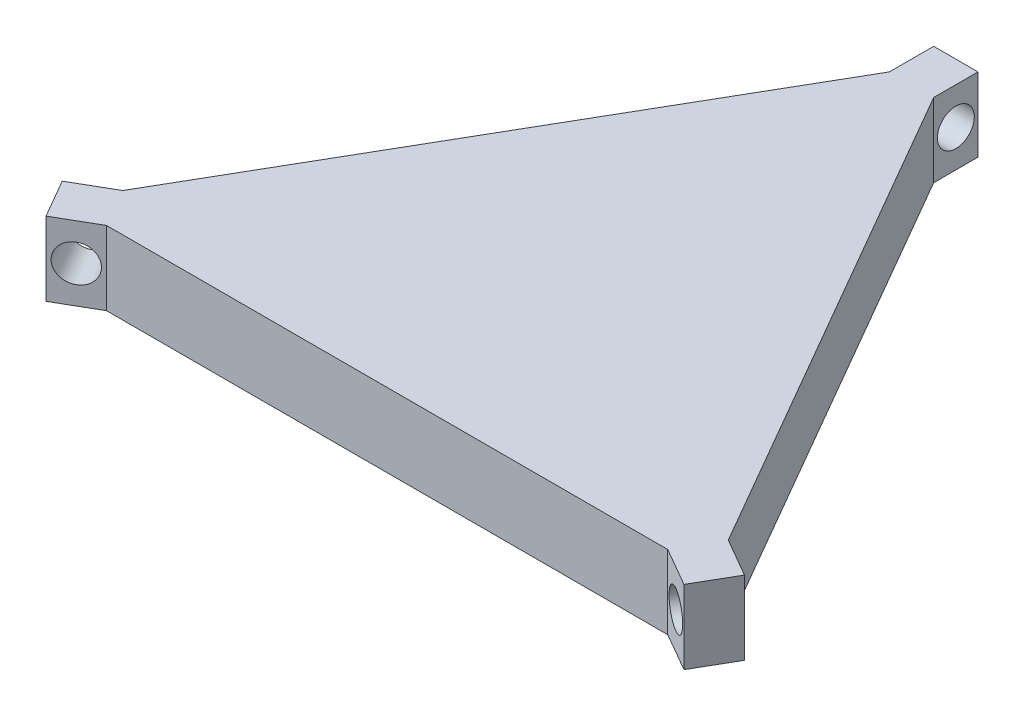
from build123d import *

# Parameters (mm, degrees)
BOSS_EXTRUDE1_DEPTH = 10
SKETCH2_R           = 2.5
CUT_EXTRUDE1_DEPTH  = 88.866025
SKETCH3_R           = 2.5
CUT_EXTRUDE2_DEPTH  = 6


with BuildPart() as part:
    # Sketch1 → Boss-Extrude1 (new body)
    with BuildSketch(Plane(origin=(0, 0, 0), x_dir=(1, 0, 0), z_dir=(0, 1, 0))):
        Polygon((-3, 71.01408311), (-41, 5.196152423), (-46.196152423, 2.196152423), (-43.196152423, -3), (-38, 0), (38, 0), (43.196152423, -3), (46.196152423, 2.196152423), (41, 5.196152423), (3, 71.01408311), (3, 77.01408311), (-3, 77.01408311), align=None)
    extrude(amount=BOSS_EXTRUDE1_DEPTH)

    # Sketch2 → Cut-Extrude1 (cut)
    with BuildSketch(Plane(origin=(-9.5, 0, -16.454482672), x_dir=(0.866025404, 0, -0.5), z_dir=(0.5, 0, 0.866025404))):
        with Locations((-35.908965344, 5)):
            Circle(SKETCH2_R)
    cut_extrude1 = extrude(amount=-CUT_EXTRUDE1_DEPTH, mode=Mode.SUBTRACT)

    # Mirror6: Cut-Extrude1 across plane
    add(cut_extrude1.mirror(Plane.ZY), mode=Mode.SUBTRACT)

    # Sketch3 → Cut-Extrude2 (cut)
    with BuildSketch(Plane.ZY.offset(3)):
        with Locations((-74.01408311, 5)):
            Circle(SKETCH3_R)
    extrude(amount=-CUT_EXTRUDE2_DEPTH, mode=Mode.SUBTRACT)


solid = part.part
